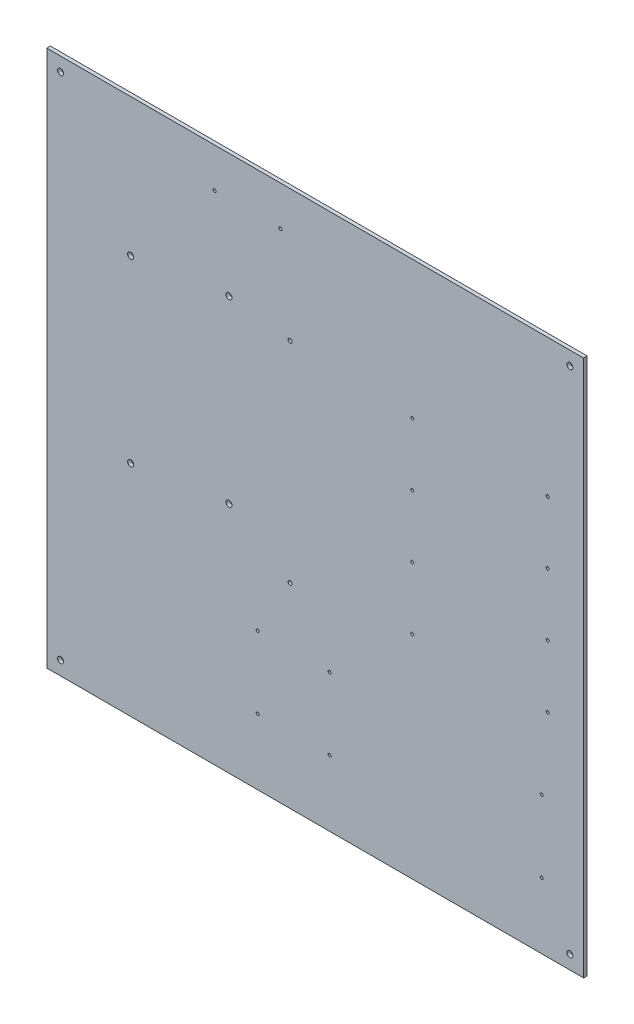
from build123d import *

# Parameters (mm, degrees)
SCHIZZO1_W                   = 448
SCHIZZO1_H                   = 448
SCHIZZO1_R                   = 2.5
SCHIZZO1_R_2                 = 1.25
SCHIZZO1_R_3                 = 1.65
ESTRUSIONE_ESTRUSIONE1_DEPTH = 3


with BuildPart() as part:
    # Schizzo1 → Estrusione-Estrusione1 (new body)
    with BuildSketch(Plane.XY):
        with Locations((224, 224)):
            Rectangle(SCHIZZO1_W, SCHIZZO1_H)
        with Locations((11.5, 436.5)):
            Circle(SCHIZZO1_R, mode=Mode.SUBTRACT)
        with Locations((436.5, 436.5)):
            Circle(SCHIZZO1_R, mode=Mode.SUBTRACT)
        with Locations((11.5, 11.5)):
            Circle(SCHIZZO1_R, mode=Mode.SUBTRACT)
        with Locations((436.5, 11.5)):
            Circle(SCHIZZO1_R, mode=Mode.SUBTRACT)
        with Locations((418, 177)):
            Circle(SCHIZZO1_R_2, mode=Mode.SUBTRACT)
        with Locations((305, 177)):
            Circle(SCHIZZO1_R_2, mode=Mode.SUBTRACT)
        with Locations((418, 229)):
            Circle(SCHIZZO1_R_2, mode=Mode.SUBTRACT)
        with Locations((305, 229)):
            Circle(SCHIZZO1_R_2, mode=Mode.SUBTRACT)
        with Locations((418, 281)):
            Circle(SCHIZZO1_R_2, mode=Mode.SUBTRACT)
        with Locations((305, 281)):
            Circle(SCHIZZO1_R_2, mode=Mode.SUBTRACT)
        with Locations((418, 333)):
            Circle(SCHIZZO1_R_2, mode=Mode.SUBTRACT)
        with Locations((305, 333)):
            Circle(SCHIZZO1_R_2, mode=Mode.SUBTRACT)
        with Locations((140, 415)):
            Circle(SCHIZZO1_R_2, mode=Mode.SUBTRACT)
        with Locations((195, 415)):
            Circle(SCHIZZO1_R_2, mode=Mode.SUBTRACT)
        with Locations((70, 333)):
            Circle(SCHIZZO1_R, mode=Mode.SUBTRACT)
        with Locations((70, 183)):
            Circle(SCHIZZO1_R, mode=Mode.SUBTRACT)
        with Locations((236, 55)):
            Circle(SCHIZZO1_R_2, mode=Mode.SUBTRACT)
        with Locations((236, 115)):
            Circle(SCHIZZO1_R_2, mode=Mode.SUBTRACT)
        with Locations((413, 115)):
            Circle(SCHIZZO1_R_2, mode=Mode.SUBTRACT)
        with Locations((413, 55)):
            Circle(SCHIZZO1_R_2, mode=Mode.SUBTRACT)
        with Locations((152, 344.76958941)):
            Circle(SCHIZZO1_R, mode=Mode.SUBTRACT)
        with Locations((152, 194.76958941)):
            Circle(SCHIZZO1_R, mode=Mode.SUBTRACT)
        with Locations((203, 338)):
            Circle(SCHIZZO1_R_3, mode=Mode.SUBTRACT)
        with Locations((203, 163)):
            Circle(SCHIZZO1_R_3, mode=Mode.SUBTRACT)
        with Locations((176, 115)):
            Circle(SCHIZZO1_R_2, mode=Mode.SUBTRACT)
        with Locations((176, 55)):
            Circle(SCHIZZO1_R_2, mode=Mode.SUBTRACT)
    extrude(amount=-ESTRUSIONE_ESTRUSIONE1_DEPTH)


solid = part.part
